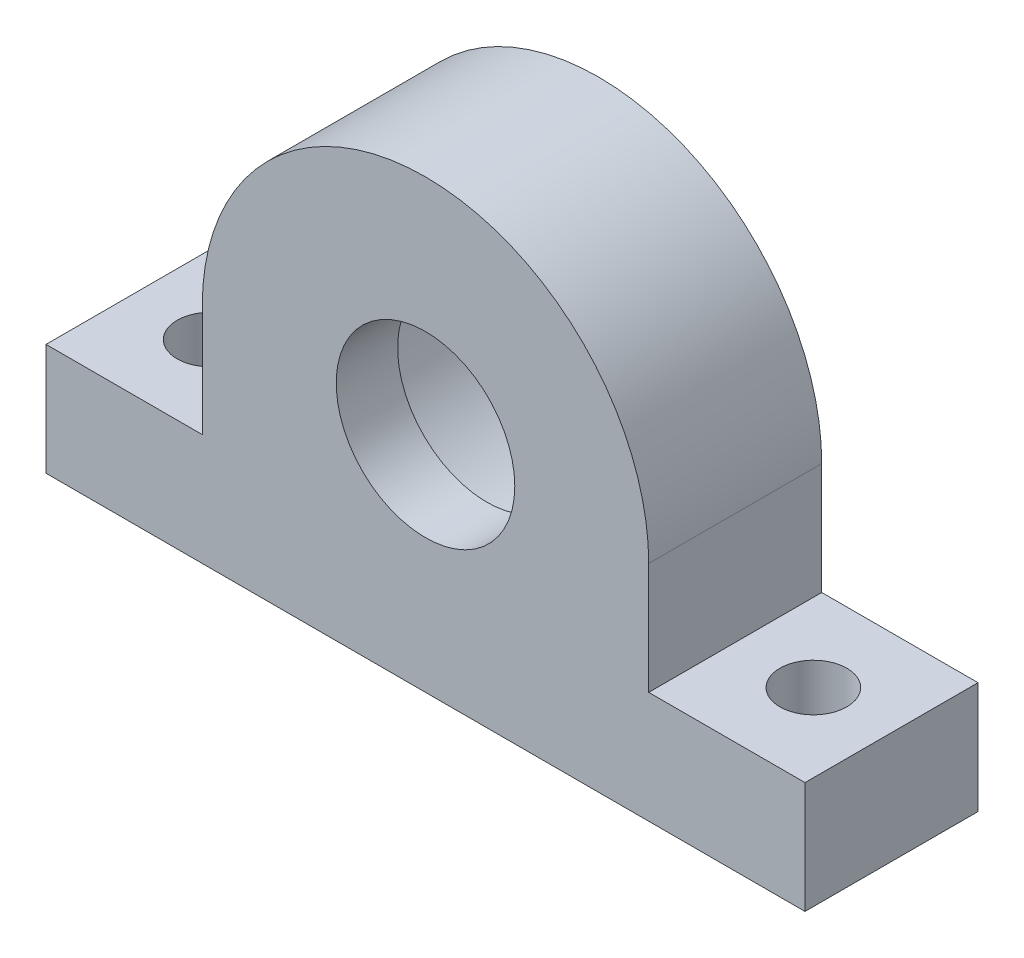
from build123d import *

# Parameters (mm, degrees)
SKETCH1_R           = 13.05
BOSS_EXTRUDE1_DEPTH = 10
SKETCH2_R           = 8
BOSS_EXTRUDE2_DEPTH = 5.5
SKETCH3_R           = 3
CUT_EXTRUDE1_DEPTH  = 11


with BuildPart() as part:
    # Sketch1 → Boss-Extrude1 (new body)
    with BuildSketch(Plane.XY):
        with BuildLine():
            Line((-34, 0), (34, 0))
            Line((34, 0), (34, 10))
            Line((34, 10), (20, 10))
            Line((20, 10), (20, 20))
            ThreePointArc((20, 20), (0, 40), (-20, 20))
            Line((-20, 20), (-20, 10))
            Line((-20, 10), (-34, 10))
            Line((-34, 10), (-34, 0))
        make_face()
        with Locations((0, 20)):
            Circle(SKETCH1_R, mode=Mode.SUBTRACT)
    extrude(amount=BOSS_EXTRUDE1_DEPTH)

    # Sketch2 → Boss-Extrude2 (add)
    with BuildSketch(Plane.XY.offset(10)):
        with BuildLine():
            Line((34, 0), (34, 10))
            Line((34, 10), (20, 10))
            Line((20, 10), (20, 20))
            ThreePointArc((20, 20), (0, 40), (-20, 20))
            Line((-20, 20), (-20, 10))
            Line((-20, 10), (-34, 10))
            Line((-34, 10), (-34, 0))
            Line((-34, 0), (34, 0))
        make_face()
        with Locations((0, 20)):
            Circle(SKETCH2_R, mode=Mode.SUBTRACT)
    extrude(amount=BOSS_EXTRUDE2_DEPTH)

    # Sketch3 → Cut-Extrude1 (cut, through all)
    with BuildSketch(Plane(origin=(0, 10, 0), x_dir=(1, 0, 0), z_dir=(0, 1, 0))):
        with Locations((27, -7.75)):
            Circle(SKETCH3_R)
        with Locations((-27, -7.75)):
            Circle(SKETCH3_R)
    extrude(amount=-CUT_EXTRUDE1_DEPTH, mode=Mode.SUBTRACT)


solid = part.part
